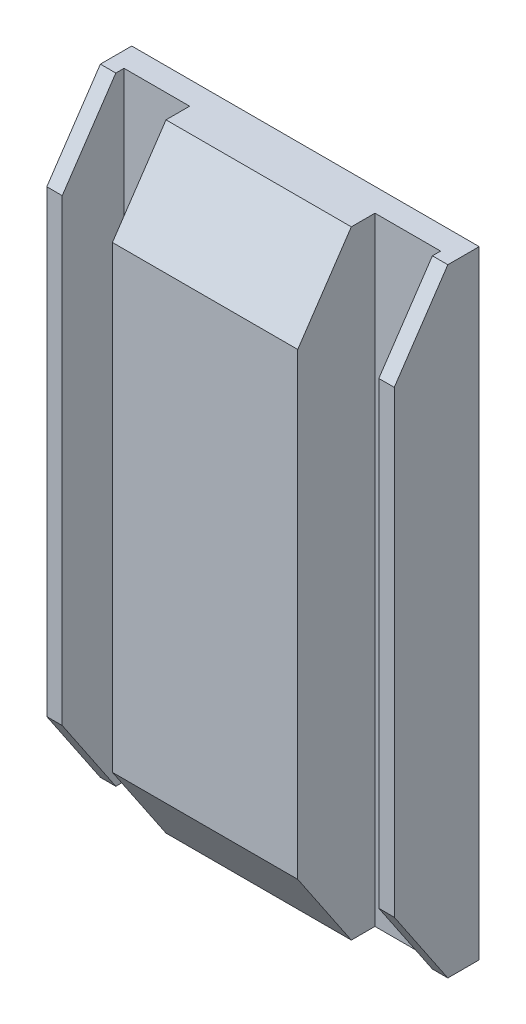
from build123d import *

# Parameters (mm, degrees)
SKETCH1_W             = 114.3
SKETCH1_H             = 203.2
BOSS_EXTRUDE1_DEPTH   = 33.02
SKETCH2_W             = 26.67
SKETCH2_H             = 25.4
CUT_EXTRUDE1_DEPTH    = 204.2
CHAMFER1_SIZE         = 17.62
CHAMFER1_SIZE2        = 26.122724265
CHAMFER1_PART_2_SIZE  = 17.62
CHAMFER1_PART_2_SIZE2 = 26.122724265
SKETCH3_W             = 5.08
SKETCH3_H             = 203.2
BOSS_EXTRUDE2_DEPTH   = 20.32
CHAMFER2_SIZE         = 17.62
CHAMFER2_SIZE2        = 26.122724265
CHAMFER2_PART_2_SIZE  = 17.62
CHAMFER2_PART_2_SIZE2 = 26.122724265
SKETCH5_W             = 76.2
SKETCH5_H             = 76.2
CUT_EXTRUDE2_DEPTH    = 2.54


with BuildPart() as part:
    # Sketch1 → Boss-Extrude1 (new body)
    with BuildSketch(Plane.XY):
        with Locations((97.239666667, -13.292666667)):
            Rectangle(SKETCH1_W, SKETCH1_H)
    extrude(amount=BOSS_EXTRUDE1_DEPTH)

    # Sketch2 → Cut-Extrude1 (cut, through all)
    with BuildSketch(Plane(origin=(0, 88.307333333, 0), x_dir=(1, 0, 0), z_dir=(0, 1, 0))):
        with Locations((53.424666667, -20.32)):
            Rectangle(SKETCH2_W, SKETCH2_H)
        with Locations((141.054666667, -20.32)):
            Rectangle(SKETCH2_W, SKETCH2_H)
    extrude(amount=-CUT_EXTRUDE1_DEPTH, mode=Mode.SUBTRACT)

    # Chamfer1
    chamfer1_edges = [part.edges().sort_by_distance(p)[0] for p in [
        (97.239666667, -114.892666667, 33.02),
    ]]
    chamfer1_side = [part.faces().sort_by_distance(p)[0] for p in [
        (97.239666667, -114.892666667, 14.3764),
    ]]
    chamfer(chamfer1_edges, length=CHAMFER1_SIZE, length2=CHAMFER1_SIZE2, reference=chamfer1_side[0])

    # Chamfer1 part 2
    chamfer1_part_2_edges = [part.edges().sort_by_distance(p)[0] for p in [
        (97.239666667, 88.307333333, 33.02),
    ]]
    chamfer1_part_2_side = [part.faces().sort_by_distance(p)[0] for p in [
        (97.239666667, 88.307333333, 14.3764),
    ]]
    chamfer(chamfer1_part_2_edges, length=CHAMFER1_PART_2_SIZE, length2=CHAMFER1_PART_2_SIZE2, reference=chamfer1_part_2_side[0])

    # Sketch3 → Boss-Extrude2 (add)
    with BuildSketch(Plane.XY.offset(7.62)):
        with Locations((42.629666667, -13.292666667)):
            Rectangle(SKETCH3_W, SKETCH3_H)
        with Locations((151.849666667, -13.292666667)):
            Rectangle(SKETCH3_W, SKETCH3_H)
    extrude(amount=BOSS_EXTRUDE2_DEPTH)

    # Chamfer2
    chamfer2_edges = [part.edges().sort_by_distance(p)[0] for p in [
        (42.629666667, -114.892666667, 27.94),
        (151.849666667, -114.892666667, 27.94),
    ]]
    chamfer2_side = [part.faces().sort_by_distance(p)[0] for p in [
        (97.239666667, -114.892666667, 8.022187919),
    ]]
    chamfer(chamfer2_edges, length=CHAMFER2_SIZE, length2=CHAMFER2_SIZE2, reference=chamfer2_side[0])

    # Chamfer2 part 2
    chamfer2_part_2_edges = [part.edges().sort_by_distance(p)[0] for p in [
        (42.629666667, 88.307333333, 27.94),
        (151.849666667, 88.307333333, 27.94),
    ]]
    chamfer2_part_2_side = [part.faces().sort_by_distance(p)[0] for p in [
        (97.239666667, 88.307333333, 8.022187919),
    ]]
    chamfer(chamfer2_part_2_edges, length=CHAMFER2_PART_2_SIZE, length2=CHAMFER2_PART_2_SIZE2, reference=chamfer2_part_2_side[0])

    # Sketch5 → Cut-Extrude2 (cut)
    with BuildSketch(Plane(origin=(0, 0, 0), x_dir=(-1, 0, 0), z_dir=(0, 0, -1))):
        with Locations((-97.239666667, 24.807333333)):
            Rectangle(SKETCH5_W, SKETCH5_H)
    extrude(amount=-CUT_EXTRUDE2_DEPTH, mode=Mode.SUBTRACT)


solid = part.part
